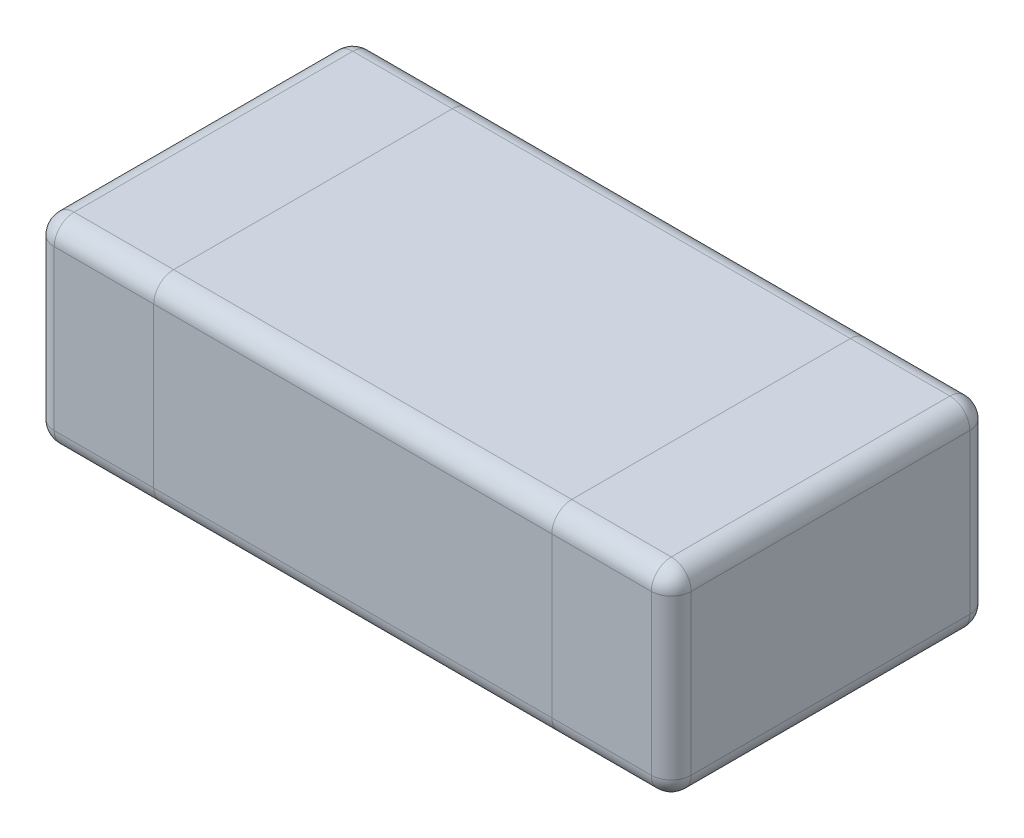
from build123d import *

# Parameters (mm, degrees)
SKETCH1_W             = 0.3
SKETCH1_H             = 0.8
BOSS_EXTRUDE1_DEPTH   = 0.5
BOSS_EXTRUDE1_2_DEPTH = 0.5
SKETCH2_W             = 1
SKETCH2_H             = 0.8
BOSS_EXTRUDE2_DEPTH   = 0.5
FILLET1_R             = 0.05
FILLET2_R             = 0.05
FILLET3_R             = 0.05


with BuildPart() as part:
    # Sketch1 → Boss-Extrude1 (new body)
    with BuildSketch(Plane(origin=(0, 0, 0), x_dir=(1, 0, 0), z_dir=(0, 1, 0))):
        with Locations((0.15, 0.4)):
            Rectangle(SKETCH1_W, SKETCH1_H)
    extrude(amount=BOSS_EXTRUDE1_DEPTH)

    # Fillet1
    fillet1_edges = [part.edges().sort_by_distance(p)[0] for p in [
        (0.15, 0.5, -0.8),
        (0, 0.5, -0.4),
        (0.15, 0, -0.8),
        (0.15, 0, 0),
        (0, 0, -0.4),
        (0.15, 0.5, 0),
        (0, 0.25, -0.8),
        (0, 0.25, 0),
    ]]
    fillet(fillet1_edges, radius=FILLET1_R)


with BuildPart() as body_2:
    # Sketch1 → Boss-Extrude1 2 (new body)
    with BuildSketch(Plane(origin=(0, 0, 0), x_dir=(1, 0, 0), z_dir=(0, 1, 0))):
        with Locations((1.45, 0.4)):
            Rectangle(SKETCH1_W, SKETCH1_H)
    extrude(amount=BOSS_EXTRUDE1_2_DEPTH)

    # Fillet2
    fillet2_edges = [body_2.edges().sort_by_distance(p)[0] for p in [
        (1.6, 0.5, -0.4),
        (1.45, 0.5, -0.8),
        (1.45, 0, -0.8),
        (1.6, 0, -0.4),
        (1.45, 0, 0),
        (1.45, 0.5, 0),
        (1.6, 0.25, -0.8),
        (1.6, 0.25, 0),
    ]]
    fillet(fillet2_edges, radius=FILLET2_R)


with BuildPart() as body_3:
    # Sketch2 → Boss-Extrude2 (new body)
    with BuildSketch(Plane(origin=(0, 0, 0), x_dir=(1, 0, 0), z_dir=(0, 1, 0))):
        with Locations((0.8, 0.4)):
            Rectangle(SKETCH2_W, SKETCH2_H)
    extrude(amount=BOSS_EXTRUDE2_DEPTH)

    # Fillet3
    fillet3_edges = [body_3.edges().sort_by_distance(p)[0] for p in [
        (0.8, 0.5, -0.8),
        (0.8, 0, -0.8),
        (0.8, 0, 0),
        (0.8, 0.5, 0),
    ]]
    fillet(fillet3_edges, radius=FILLET3_R)


solid = Compound([part.part, body_2.part, body_3.part])
